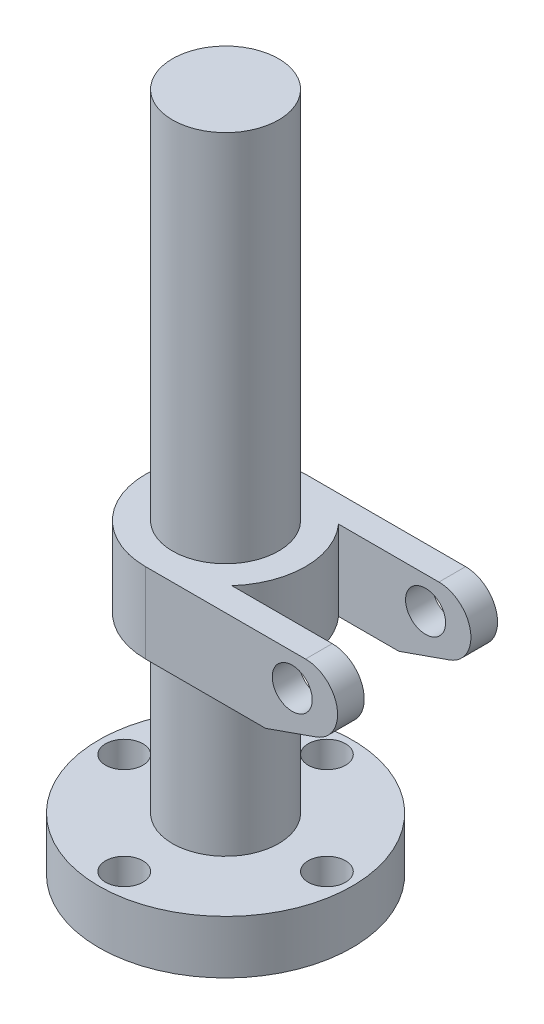
from build123d import *

# Parameters (mm, degrees)
SKETCH3_R                                = 7.5
BOSS_EXTRUDE1_DEPTH                      = 47.5
BOSS_EXTRUDE1_DEPTH_BACK                 = 47.5
CUT_EXTRUDE1_REACH                       = 166.439
SKETCH4_W                                = 60
SKETCH4_H                                = 17.5
SKETCH4_W_2                              = 12
SKETCH4_H_2                              = 20
CBORE_FOR_M20_HEX_HEAD_BOLT1_D           = 10
CBORE_FOR_M20_HEX_HEAD_BOLT1_CBORE_D     = 14
CBORE_FOR_M20_HEX_HEAD_BOLT1_CBORE_DEPTH = 10


with BuildPart() as part:
    # Sketch2 → Revolve1 (revolve)
    with BuildSketch(Plane.XY, mode=Mode.PRIVATE) as revolve1_sk:
        Polygon((-47.5, 0), (-20, 0), (-20, 15), (0, 15), (0, 255), (-19.9, 255), (-19.9, 115), (-30, 115), (-30, 85), (-19.9, 85), (-19.9, 20), (-47.5, 20), align=None)
    revolve(revolve1_sk.sketch.rotate(Axis((0, 255, 0), (0, -1, 0)), 270), axis=Axis((0, 255, 0), (0, -1, 0)))

    # Sketch3 → Boss-Extrude1 (add, two sides)
    with BuildSketch(Plane.XY) as boss_extrude1_sk:
        with BuildLine():
            Line((0, 115), (60, 115))
            ThreePointArc((60, 115), (71.828663031, 105.020576871), (63.983453822, 91.680455148))
            Line((63.983453822, 91.680455148), (45, 85))
            Line((45, 85), (30, 85))
            Line((30, 85), (0, 85))
            Line((0, 85), (0, 115))
        make_face()
        with Locations((55, 103)):
            Circle(SKETCH3_R, mode=Mode.SUBTRACT)
    extrude(amount=BOSS_EXTRUDE1_DEPTH)
    extrude(boss_extrude1_sk.sketch, amount=-BOSS_EXTRUDE1_DEPTH_BACK)

    # Sketch4 → Cut-Extrude1 (cut, up to next)
    with BuildSketch(Plane(origin=(0, 115, 0), x_dir=(1, 0, 0), z_dir=(0, 1, 0)), mode=Mode.PRIVATE) as cut_extrude1_sk1:
        with Locations((30, -38.75)):
            Rectangle(SKETCH4_W, SKETCH4_H)
    cut_extrude1_tool1 = extrude(cut_extrude1_sk1.sketch, amount=-CUT_EXTRUDE1_REACH, mode=Mode.PRIVATE) & part.part
    # Sketch4 → Cut-Extrude1 (cut, up to next)
    with BuildSketch(Plane(origin=(0, 115, 0), x_dir=(1, 0, 0), z_dir=(0, 1, 0)), mode=Mode.PRIVATE) as cut_extrude1_sk2:
        with Locations((66, -38.75)):
            Rectangle(SKETCH4_W_2, SKETCH4_H)
    cut_extrude1_tool2 = extrude(cut_extrude1_sk2.sketch, amount=-CUT_EXTRUDE1_REACH, mode=Mode.PRIVATE) & part.part
    # Sketch4 → Cut-Extrude1 (cut, up to next)
    with BuildSketch(Plane(origin=(0, 115, 0), x_dir=(1, 0, 0), z_dir=(0, 1, 0)), mode=Mode.PRIVATE) as cut_extrude1_sk3:
        with BuildLine():
            ThreePointArc((30, 0), (28.025170769, -10.704662693), (22.360679775, -20))
            Line((22.360679775, -20), (60, -20))
            Line((60, -20), (60, 0))
            Line((60, 0), (30, 0))
        make_face()
    cut_extrude1_tool3 = extrude(cut_extrude1_sk3.sketch, amount=-CUT_EXTRUDE1_REACH, mode=Mode.PRIVATE) & part.part
    # Sketch4 → Cut-Extrude1 (cut, up to next)
    with BuildSketch(Plane(origin=(0, 115, 0), x_dir=(1, 0, 0), z_dir=(0, 1, 0)), mode=Mode.PRIVATE) as cut_extrude1_sk4:
        with Locations((66, -10)):
            Rectangle(SKETCH4_W_2, SKETCH4_H_2)
    cut_extrude1_tool4 = extrude(cut_extrude1_sk4.sketch, amount=-CUT_EXTRUDE1_REACH, mode=Mode.PRIVATE) & part.part
    # Sketch4 → Cut-Extrude1 (cut, up to next)
    with BuildSketch(Plane(origin=(0, 115, 0), x_dir=(1, 0, 0), z_dir=(0, 1, 0)), mode=Mode.PRIVATE) as cut_extrude1_sk5:
        with BuildLine():
            Line((60, 20), (22.360679775, 20))
            ThreePointArc((22.360679775, 20), (28.025170769, 10.704662693), (30, 0))
            Line((30, 0), (60, 0))
            Line((60, 0), (60, 20))
        make_face()
    cut_extrude1_tool5 = extrude(cut_extrude1_sk5.sketch, amount=-CUT_EXTRUDE1_REACH, mode=Mode.PRIVATE) & part.part
    # Sketch4 → Cut-Extrude1 (cut, up to next)
    with BuildSketch(Plane(origin=(0, 115, 0), x_dir=(1, 0, 0), z_dir=(0, 1, 0)), mode=Mode.PRIVATE) as cut_extrude1_sk6:
        with Locations((66, 10)):
            Rectangle(SKETCH4_W_2, SKETCH4_H_2)
    cut_extrude1_tool6 = extrude(cut_extrude1_sk6.sketch, amount=-CUT_EXTRUDE1_REACH, mode=Mode.PRIVATE) & part.part
    # Sketch4 → Cut-Extrude1 (cut, up to next)
    with BuildSketch(Plane(origin=(0, 115, 0), x_dir=(1, 0, 0), z_dir=(0, 1, 0)), mode=Mode.PRIVATE) as cut_extrude1_sk7:
        with Locations((30, 38.75)):
            Rectangle(SKETCH4_W, SKETCH4_H)
    cut_extrude1_tool7 = extrude(cut_extrude1_sk7.sketch, amount=-CUT_EXTRUDE1_REACH, mode=Mode.PRIVATE) & part.part
    # Sketch4 → Cut-Extrude1 (cut, up to next)
    with BuildSketch(Plane(origin=(0, 115, 0), x_dir=(1, 0, 0), z_dir=(0, 1, 0)), mode=Mode.PRIVATE) as cut_extrude1_sk8:
        with Locations((66, 38.75)):
            Rectangle(SKETCH4_W_2, SKETCH4_H)
    cut_extrude1_tool8 = extrude(cut_extrude1_sk8.sketch, amount=-CUT_EXTRUDE1_REACH, mode=Mode.PRIVATE) & part.part
    add(cut_extrude1_tool1.solids().sort_by_distance((30, 115, 38.75))[0], mode=Mode.SUBTRACT)
    add(cut_extrude1_tool2.solids().sort_by_distance((66, 115, 38.75))[0], mode=Mode.SUBTRACT)
    add(cut_extrude1_tool3.solids().sort_by_distance((43.723217, 115, 10.380581))[0], mode=Mode.SUBTRACT)
    add(cut_extrude1_tool4.solids().sort_by_distance((66, 115, 10))[0], mode=Mode.SUBTRACT)
    add(cut_extrude1_tool5.solids().sort_by_distance((43.723217, 115, -10.380581))[0], mode=Mode.SUBTRACT)
    add(cut_extrude1_tool6.solids().sort_by_distance((66, 115, -10))[0], mode=Mode.SUBTRACT)
    add(cut_extrude1_tool7.solids().sort_by_distance((30, 115, -38.75))[0], mode=Mode.SUBTRACT)
    add(cut_extrude1_tool8.solids().sort_by_distance((66, 115, -38.75))[0], mode=Mode.SUBTRACT)

    # CBORE for M20 Hex Head Bolt1 (through all)
    with Locations(Plane(origin=(0, 20, 0), x_dir=(1, 0, 0), z_dir=(0, 1, 0))):
        with Locations((38, 0), (0, 38), (-38, 0), (0, -38)):
            CounterBoreHole(CBORE_FOR_M20_HEX_HEAD_BOLT1_D / 2, CBORE_FOR_M20_HEX_HEAD_BOLT1_CBORE_D / 2, CBORE_FOR_M20_HEX_HEAD_BOLT1_CBORE_DEPTH)


solid = part.part
